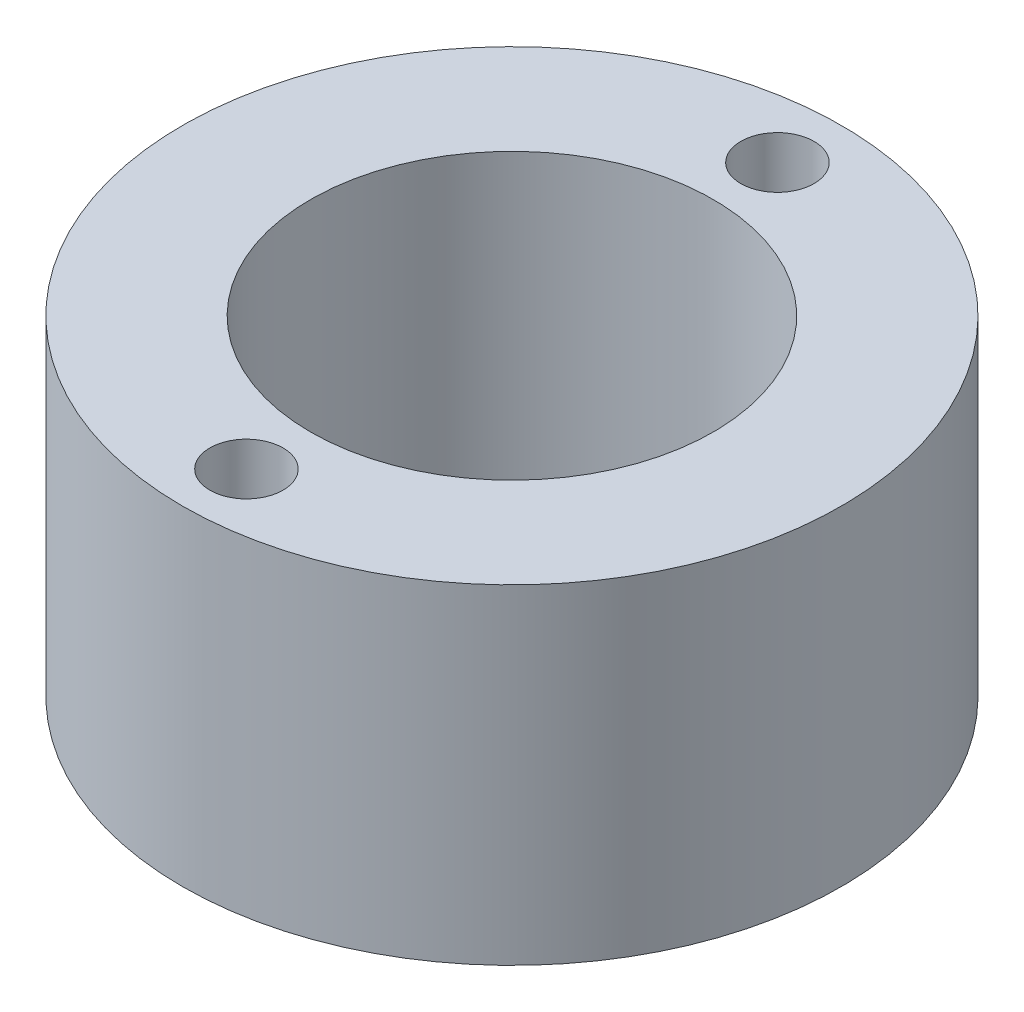
from build123d import *

# Parameters (mm, degrees)
SKETCH1_R           = 9
BOSS_EXTRUDE1_DEPTH = 9
SKETCH2_R           = 5.5
CUT_EXTRUDE1_DEPTH  = 8
SKETCH3_R           = 1
CUT_EXTRUDE2_DEPTH  = 3


with BuildPart() as part:
    # Sketch1 → Boss-Extrude1 (new body)
    with BuildSketch(Plane(origin=(0, 0, 0), x_dir=(1, 0, 0), z_dir=(0, 1, 0))):
        Circle(SKETCH1_R)
    extrude(amount=BOSS_EXTRUDE1_DEPTH)

    # Sketch2 → Cut-Extrude1 (cut)
    with BuildSketch(Plane(origin=(0, 9, 0), x_dir=(1, 0, 0), z_dir=(0, 1, 0))):
        Circle(SKETCH2_R)
    extrude(amount=-CUT_EXTRUDE1_DEPTH, mode=Mode.SUBTRACT)

    # Sketch3 → Cut-Extrude2 (cut)
    with BuildSketch(Plane(origin=(0, 9, 0), x_dir=(1, 0, 0), z_dir=(0, 1, 0))):
        with Locations((0, 7.25)):
            Circle(SKETCH3_R)
        with Locations((0, -7.25)):
            Circle(SKETCH3_R)
    extrude(amount=-CUT_EXTRUDE2_DEPTH, mode=Mode.SUBTRACT)


solid = part.part
